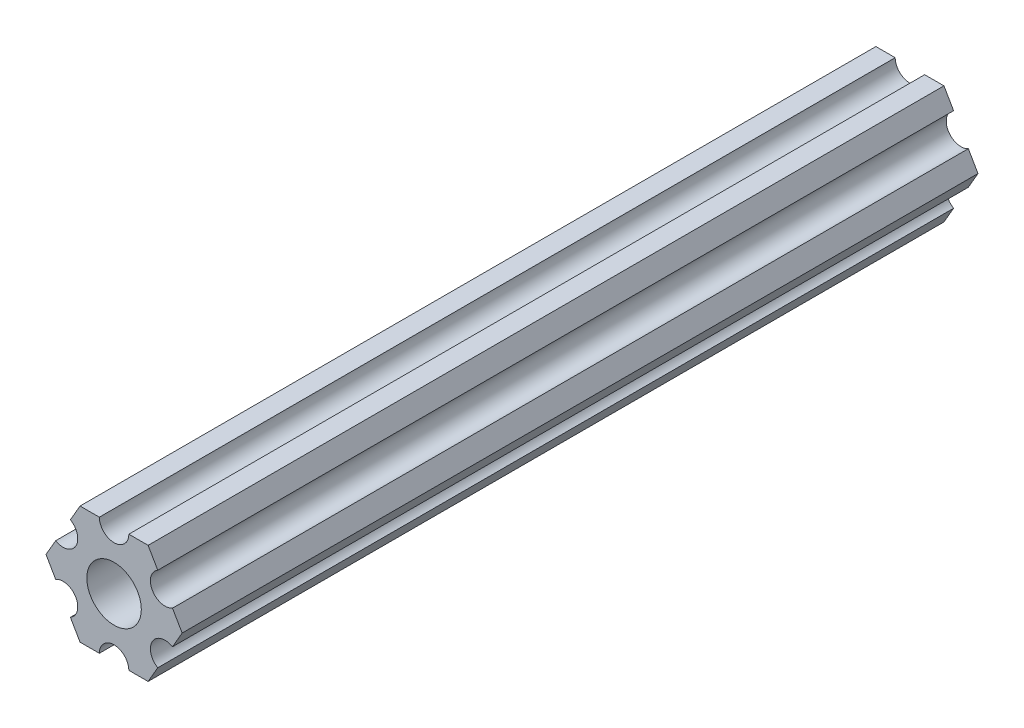
from build123d import *

# Parameters (mm, degrees)
SKETCH1_R           = 2.9337
BOSS_EXTRUDE1_DEPTH = 85.725


with BuildPart() as part:
    # Sketch1 → Boss-Extrude1 (new body)
    with BuildSketch(Plane(origin=(0, 0, 0), x_dir=(-1, 0, 0), z_dir=(0, 0, -1))):
        with BuildLine():
            Line((-4.70551159, -4.549815043), (-3.666174546, -6.349999862))
            Line((-3.666174546, -6.349999862), (-1.587500385, -6.349999862))
            ThreePointArc((-1.587500385, -6.349999862), (-3.85e-07, -4.762499862), (1.587499615, -6.349999862))
            Line((1.587499615, -6.349999862), (3.666173825, -6.349999862))
            Line((3.666173825, -6.349999862), (4.705510942, -4.549815198))
            ThreePointArc((4.705510942, -4.549815198), (4.124445629, -2.381249865), (6.293010962, -1.800184552))
            Line((6.293010962, -1.800184552), (7.332348079, 1.12e-07))
            Line((7.332348079, 1.12e-07), (6.293011217, 1.800184727))
            ThreePointArc((6.293011217, 1.800184727), (4.124445939, 2.381250245), (4.705511457, 4.549815523))
            Line((4.705511457, 4.549815523), (3.666174546, 6.350000222))
            Line((3.666174546, 6.350000222), (1.587500385, 6.350000222))
            ThreePointArc((1.587500385, 6.350000222), (3.85e-07, 4.762500222), (-1.587499615, 6.350000222))
            Line((-1.587499615, 6.350000222), (-3.666173825, 6.350000222))
            Line((-3.666173825, 6.350000222), (-4.705511038, 4.549815614))
            ThreePointArc((-4.705511038, 4.549815614), (-4.124445841, 2.38125025), (-6.293011205, 1.800185053))
            Line((-6.293011205, 1.800185053), (-7.332348419, 4.44e-07))
            Line((-7.332348419, 4.44e-07), (-6.293011423, -1.80018429))
            ThreePointArc((-6.293011423, -1.80018429), (-4.12444613, -2.38124975), (-4.70551159, -4.549815043))
        make_face()
        Circle(SKETCH1_R, mode=Mode.SUBTRACT)
    extrude(amount=-BOSS_EXTRUDE1_DEPTH)


solid = part.part
